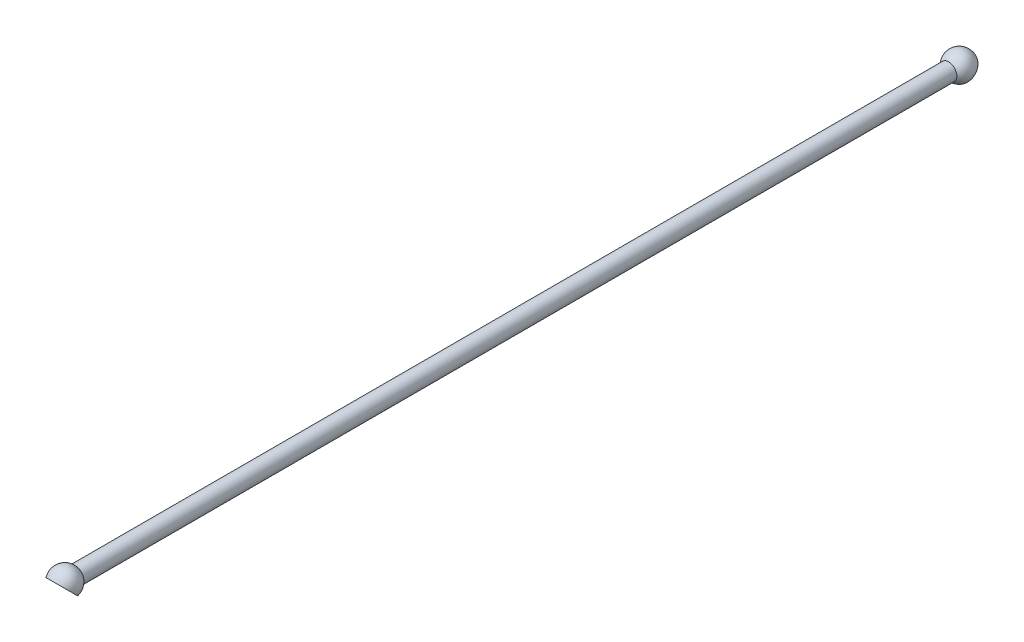
from build123d import *

# Parameters (mm, degrees)
SKETCH1_R                = 4
BOSS_EXTRUDE1_DEPTH      = 214.080811
BOSS_EXTRUDE1_DEPTH_BACK = 214.080811
CUT_EXTRUDE1_START       = -10.192388155
SKETCH5_W                = 20
SKETCH5_H                = 5
CUT_EXTRUDE1_DEPTH       = 318.544568669


with BuildPart() as part:
    # Sketch1 → Boss-Extrude1 (new body, two sides)
    with BuildSketch(Plane.XY) as boss_extrude1_sk:
        Circle(SKETCH1_R)
    extrude(amount=BOSS_EXTRUDE1_DEPTH)
    extrude(boss_extrude1_sk.sketch, amount=-BOSS_EXTRUDE1_DEPTH_BACK)

    # Sketch3 → Revolve1 (revolve)
    with BuildSketch(Plane(origin=(0, 0, 0), x_dir=(0, 0, -1), z_dir=(1, 0, 0))):
        with BuildLine():
            Line((-220.580811107, 0), (-207.580811107, 0))
            ThreePointArc((-207.580811107, 0), (-214.080811107, 6.5), (-220.580811107, 0))
        make_face()
    revolve1 = revolve(axis=Axis((0, 0, 220.580811107), (0, 0, -1)))

    # Sketch5 → Cut-Extrude1 (cut)
    with BuildSketch(Plane(origin=(0, 107.040405554, 107.040405554), x_dir=(1, 0, 0), z_dir=(0, -0.707106781, -0.707106781)).offset(CUT_EXTRUDE1_START)):
        with Locations((0, 155.877993256)):
            Rectangle(SKETCH5_W, SKETCH5_H)
    cut_extrude1 = extrude(amount=CUT_EXTRUDE1_DEPTH, mode=Mode.SUBTRACT)

    # Sketch6 → Cut-Revolve1 (revolve, cut)
    with BuildSketch(Plane(origin=(0, 0, 0), x_dir=(1, 0, 0), z_dir=(0, 1, 0))):
        with BuildLine():
            Line((0, -209.080811107), (0, -219.080811107))
            ThreePointArc((0, -219.080811107), (5, -214.080811107), (0, -209.080811107))
        make_face()
    cut_revolve1 = revolve(axis=Axis((0, 0, 209.080811107), (0, 0, 1)), mode=Mode.SUBTRACT)

    # Mirror2: Revolve1, Cut-Extrude1, Cut-Revolve1 across plane
    add(revolve1.mirror(Plane.XY))
    add(cut_extrude1.mirror(Plane.XY), mode=Mode.SUBTRACT)
    add(cut_revolve1.mirror(Plane.XY), mode=Mode.SUBTRACT)


solid = part.part
